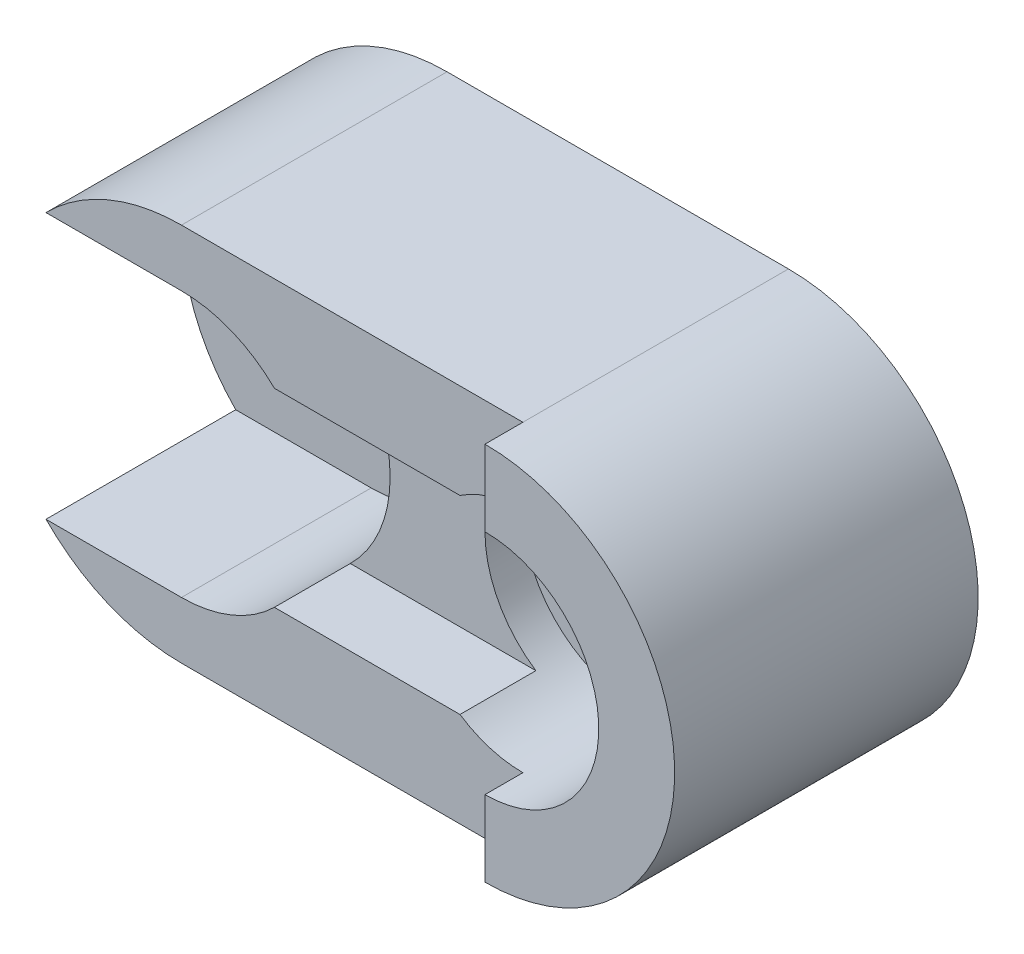
from build123d import *

# Parameters (mm, degrees)
BOSS_EXTRUDE1_DEPTH = 70
BOSS_EXTRUDE2_DEPTH = 10
SKETCH3_R           = 30
CUT_EXTRUDE1_DEPTH  = 30
SKETCH4_R           = 10
CUT_EXTRUDE2_DEPTH  = 71
CUT_EXTRUDE6_DEPTH  = 50
SKETCH9_R           = 20
CUT_EXTRUDE7_DEPTH  = 50
CUT_EXTRUDE8_DEPTH  = 20


with BuildPart() as part:
    # Sketch1 → Boss-Extrude1 (new body)
    with BuildSketch(Plane.XY):
        with BuildLine():
            Line((0, 50), (90, 50))
            ThreePointArc((90, 50), (140, 0), (90, -50))
            Line((90, -50), (0, -50))
            ThreePointArc((0, -50), (-50, 0), (0, 50))
        make_face()
    extrude(amount=BOSS_EXTRUDE1_DEPTH)

    # Sketch2 → Boss-Extrude2 (add)
    with BuildSketch(Plane.XY.offset(70)):
        with BuildLine():
            Line((90, 50), (90, 30))
            ThreePointArc((90, 30), (120, 0), (90, -30))
            Line((90, -30), (90, -50))
            ThreePointArc((90, -50), (140, 0), (90, 50))
        make_face()
    extrude(amount=BOSS_EXTRUDE2_DEPTH)

    # Sketch3 → Cut-Extrude1 (cut)
    with BuildSketch(Plane.XY.offset(70)):
        with Locations((90, 0)):
            Circle(SKETCH3_R)
    extrude(amount=-CUT_EXTRUDE1_DEPTH, mode=Mode.SUBTRACT)

    # Sketch4 → Cut-Extrude2 (cut)
    with BuildSketch(Plane.XY.offset(40)):
        with Locations((90, 0)):
            Circle(SKETCH4_R)
    extrude(amount=-CUT_EXTRUDE2_DEPTH, mode=Mode.SUBTRACT)

    # Sketch5 → Cut-Extrude6 (cut)
    with BuildSketch(Plane.XY.offset(70)):
        with BuildLine():
            Line((0, 35), (-35.707142143, 35))
            ThreePointArc((-35.707142143, 35), (-50, 0), (-35.707142143, -35))
            Line((-35.707142143, -35), (0, -35))
            ThreePointArc((0, -35), (35, 0), (0, 35))
        make_face()
    extrude(amount=-CUT_EXTRUDE6_DEPTH, mode=Mode.SUBTRACT)

    # Sketch9 → Cut-Extrude7 (cut)
    with BuildSketch(Plane.XY.offset(20)):
        Circle(SKETCH9_R)
    extrude(amount=-CUT_EXTRUDE7_DEPTH, mode=Mode.SUBTRACT)

    # Sketch10 → Cut-Extrude8 (cut)
    with BuildSketch(Plane.XY.offset(70)):
        with BuildLine():
            ThreePointArc((73.416876048, -25), (60, 0), (73.416876048, 25))
            Line((73.416876048, 25), (24.494897428, 25))
            ThreePointArc((24.494897428, 25), (35, 0), (24.494897428, -25))
            Line((24.494897428, -25), (73.416876048, -25))
        make_face()
    extrude(amount=-CUT_EXTRUDE8_DEPTH, mode=Mode.SUBTRACT)


solid = part.part
